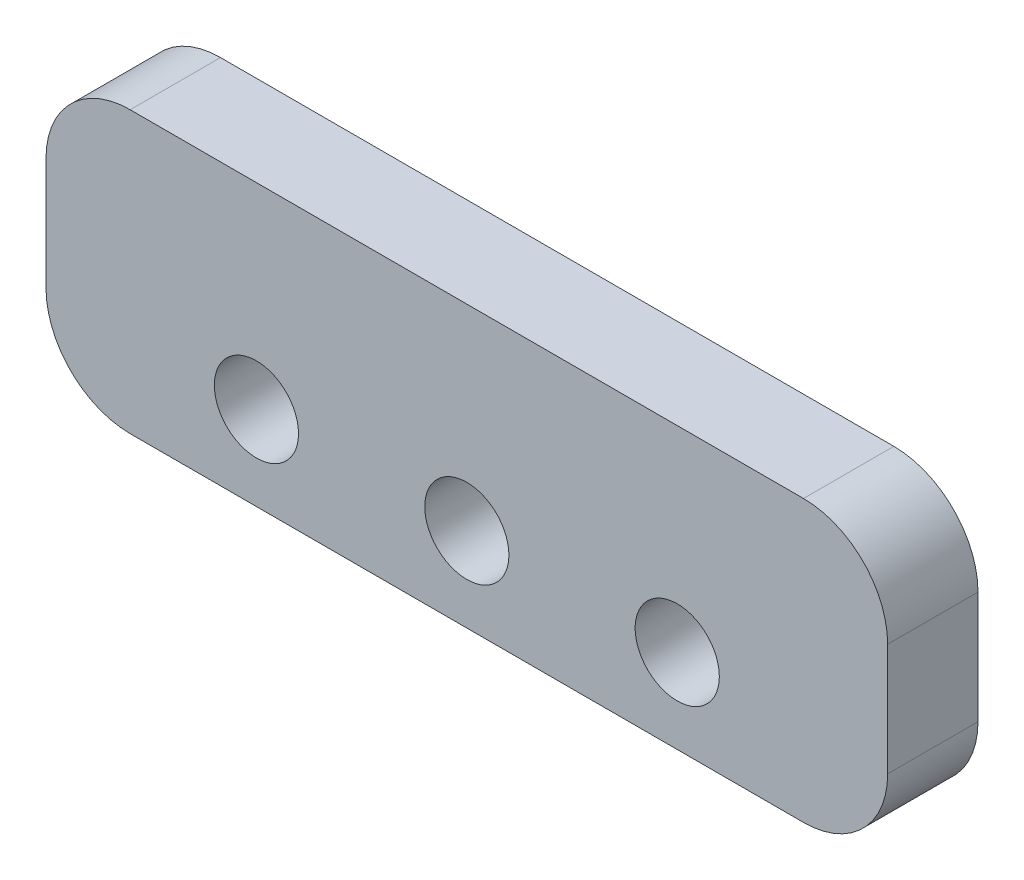
from build123d import *

# Parameters (mm, degrees)
SKETCH1_W           = 30
SKETCH1_H           = 10
SKETCH1_R           = 1.5
BOSS_EXTRUDE1_DEPTH = 1.61
FILLET1_R           = 3


with BuildPart() as part:
    # Sketch1 → Boss-Extrude1 (new body, symmetric)
    with BuildSketch(Plane.XY):
        with Locations((0, 2)):
            Rectangle(SKETCH1_W, SKETCH1_H)
        with Locations((-7.5, 0)):
            Circle(SKETCH1_R, mode=Mode.SUBTRACT)
        Circle(SKETCH1_R, mode=Mode.SUBTRACT)
        with Locations((7.5, 0)):
            Circle(SKETCH1_R, mode=Mode.SUBTRACT)
    extrude(amount=BOSS_EXTRUDE1_DEPTH, both=True)

    # Fillet1
    fillet1_edges = [part.edges().sort_by_distance(p)[0] for p in [
        (15, -3, 0),
        (-15, -3, 0),
        (-15, 7, 0),
        (15, 7, 0),
    ]]
    fillet(fillet1_edges, radius=FILLET1_R)


solid = part.part
